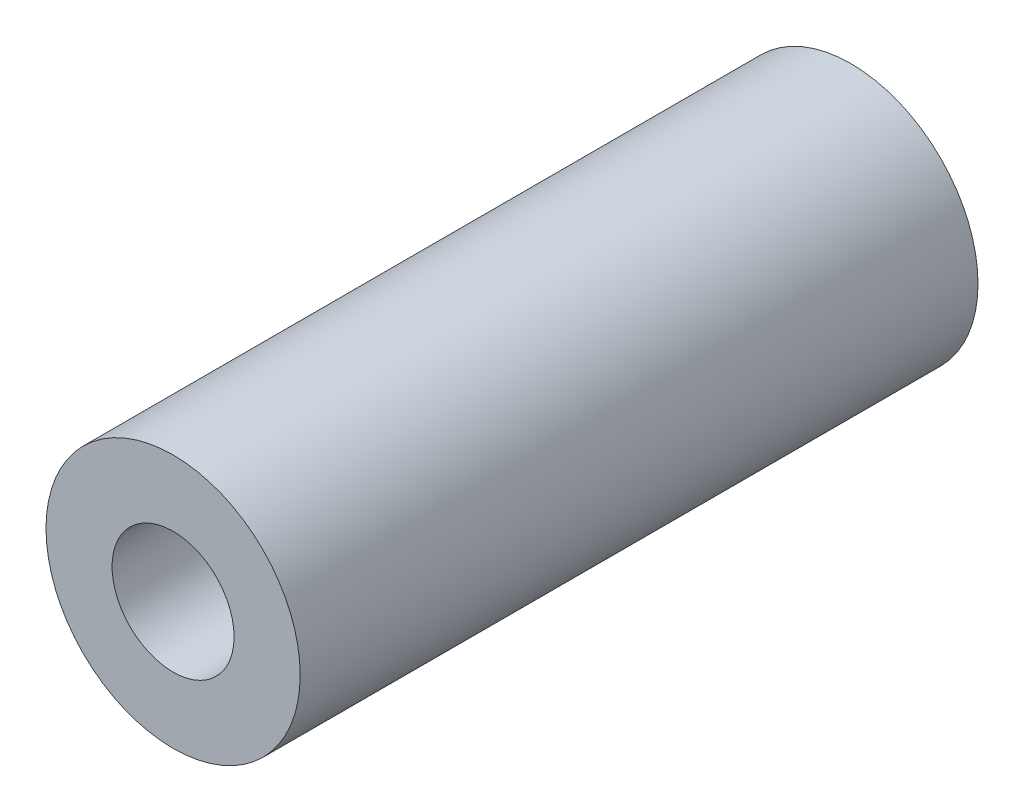
from build123d import *

# Parameters (mm, degrees)
SKETCH1_R      = 2.38125
SKETCH1_R_2    = 1.143
EXTRUDE1_DEPTH = 6.35


with BuildPart() as part:
    # Sketch1 → Extrude1 (new body, symmetric)
    with BuildSketch(Plane.XY):
        Circle(SKETCH1_R)
        Circle(SKETCH1_R_2, mode=Mode.SUBTRACT)
    extrude(amount=EXTRUDE1_DEPTH, both=True)


solid = part.part
